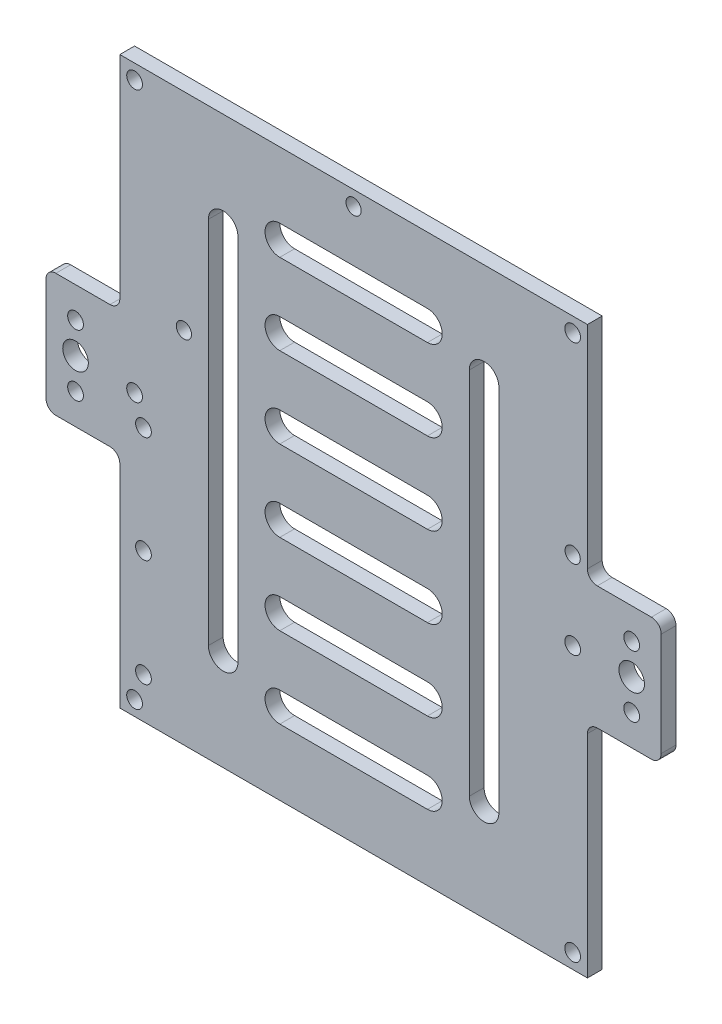
from build123d import *

# Parameters (mm, degrees)
SKETCH4_R           = 1.54999944
SKETCH4_R_2         = 1.6
SKETCH4_R_3         = 2.6
BOSS_EXTRUDE6_DEPTH = 3


with BuildPart() as part:
    # Sketch4 → Boss-Extrude6 (new body)
    with BuildSketch(Plane.XY):
        with BuildLine():
            Line((50.251854725, 14.295018861), (50.251854725, 57.295018861))
            Line((50.251854725, 57.295018861), (-44.769148998, 57.295018861))
            Line((-44.769148998, 57.295018861), (-44.769148998, 14.295018861))
            ThreePointArc((-44.769148998, 14.295018861), (-45.354935436, 12.880805298), (-46.769148998, 12.295018861))
            Line((-46.769148998, 12.295018861), (-57.769148998, 12.295018861))
            ThreePointArc((-57.769148998, 12.295018861), (-59.183362561, 11.709232423), (-59.769148998, 10.295018861))
            Line((-59.769148998, 10.295018861), (-59.769148998, -10.71398001))
            ThreePointArc((-59.769148998, -10.71398001), (-59.183362561, -12.128193573), (-57.769148998, -12.71398001))
            Line((-57.769148998, -12.71398001), (-46.769148998, -12.71398001))
            ThreePointArc((-46.769148998, -12.71398001), (-45.354935436, -13.299766448), (-44.769148998, -14.71398001))
            Line((-44.769148998, -14.71398001), (-44.769148998, -57.71398001))
            Line((-44.769148998, -57.71398001), (50.251854725, -57.71398001))
            Line((50.251854725, -57.71398001), (50.251854725, -14.71398001))
            ThreePointArc((50.251854725, -14.71398001), (50.837641163, -13.299766448), (52.251854725, -12.71398001))
            Line((52.251854725, -12.71398001), (63.251854725, -12.71398001))
            ThreePointArc((63.251854725, -12.71398001), (64.666068287, -12.128193573), (65.251854725, -10.71398001))
            Line((65.251854725, -10.71398001), (65.251854725, 10.295018861))
            ThreePointArc((65.251854725, 10.295018861), (64.666068287, 11.709232423), (63.251854725, 12.295018861))
            Line((63.251854725, 12.295018861), (52.251854725, 12.295018861))
            ThreePointArc((52.251854725, 12.295018861), (50.837641163, 12.880805298), (50.251854725, 14.295018861))
        make_face()
        with Locations((47.251855645, 15.295019041)):
            Circle(SKETCH4_R, mode=Mode.SUBTRACT)
        with Locations((2.741352863, 54.315928454)):
            Circle(SKETCH4_R, mode=Mode.SUBTRACT)
        with Locations((-31.748146375, 15.295019041)):
            Circle(SKETCH4_R, mode=Mode.SUBTRACT)
        with Locations((-41.769148998, -0.71398001)):
            Circle(SKETCH4_R_2, mode=Mode.SUBTRACT)
        with Locations((47.251854725, -0.71398001)):
            Circle(SKETCH4_R_2, mode=Mode.SUBTRACT)
        with Locations((-41.769148998, -54.71398001)):
            Circle(SKETCH4_R_2, mode=Mode.SUBTRACT)
        with Locations((47.251854725, -54.71398001)):
            Circle(SKETCH4_R_2, mode=Mode.SUBTRACT)
        with Locations((-39.969148998, -5.97675003)):
            Circle(SKETCH4_R_2, mode=Mode.SUBTRACT)
        with Locations((-39.969148998, -27.618447294)):
            Circle(SKETCH4_R_2, mode=Mode.SUBTRACT)
        with Locations((-39.969148998, -49.451209991)):
            Circle(SKETCH4_R_2, mode=Mode.SUBTRACT)
        with Locations((59.251854725, -0.209480575)):
            Circle(SKETCH4_R_3, mode=Mode.SUBTRACT)
        with Locations((-41.769148998, 54.315928454)):
            Circle(SKETCH4_R_2, mode=Mode.SUBTRACT)
        with Locations((47.251855645, 54.315928454)):
            Circle(SKETCH4_R_2, mode=Mode.SUBTRACT)
        with Locations((59.251854725, 6.042769143)):
            Circle(SKETCH4_R_2, mode=Mode.SUBTRACT)
        with Locations((59.251854725, -6.461730293)):
            Circle(SKETCH4_R_2, mode=Mode.SUBTRACT)
        with Locations((-53.769148998, -0.209480575)):
            Circle(SKETCH4_R_3, mode=Mode.SUBTRACT)
        with Locations((-53.769148998, 6.042769143)):
            Circle(SKETCH4_R_2, mode=Mode.SUBTRACT)
        with Locations((-53.769148998, -6.461730293)):
            Circle(SKETCH4_R_2, mode=Mode.SUBTRACT)
        with BuildLine():
            Line((-12.258647137, 43.865161879), (17.741352863, 43.865161879))
            ThreePointArc((17.741352863, 43.865161879), (20.741352863, 40.865161879), (17.741352863, 37.865161879))
            Line((17.741352863, 37.865161879), (-12.258647137, 37.865161879))
            ThreePointArc((-12.258647137, 37.865161879), (-15.258647137, 40.865161879), (-12.258647137, 43.865161879))
        make_face(mode=Mode.SUBTRACT)
        with BuildLine():
            Line((-12.258647137, 27.435304897), (17.741352863, 27.435304897))
            ThreePointArc((17.741352863, 27.435304897), (20.741352863, 24.435304897), (17.741352863, 21.435304897))
            Line((17.741352863, 21.435304897), (-12.258647137, 21.435304897))
            ThreePointArc((-12.258647137, 21.435304897), (-15.258647137, 24.435304897), (-12.258647137, 27.435304897))
        make_face(mode=Mode.SUBTRACT)
        with BuildLine():
            Line((-12.258647137, 11.005447916), (17.741352863, 11.005447916))
            ThreePointArc((17.741352863, 11.005447916), (20.741352863, 8.005447916), (17.741352863, 5.005447916))
            Line((17.741352863, 5.005447916), (-12.258647137, 5.005447916))
            ThreePointArc((-12.258647137, 5.005447916), (-15.258647137, 8.005447916), (-12.258647137, 11.005447916))
        make_face(mode=Mode.SUBTRACT)
        with BuildLine():
            Line((-12.258647137, -5.424409066), (17.741352863, -5.424409066))
            ThreePointArc((17.741352863, -5.424409066), (20.741352863, -8.424409066), (17.741352863, -11.424409066))
            Line((17.741352863, -11.424409066), (-12.258647137, -11.424409066))
            ThreePointArc((-12.258647137, -11.424409066), (-15.258647137, -8.424409066), (-12.258647137, -5.424409066))
        make_face(mode=Mode.SUBTRACT)
        with BuildLine():
            Line((-12.258647137, -21.854266047), (17.741352863, -21.854266047))
            ThreePointArc((17.741352863, -21.854266047), (20.741352863, -24.854266047), (17.741352863, -27.854266047))
            Line((17.741352863, -27.854266047), (-12.258647137, -27.854266047))
            ThreePointArc((-12.258647137, -27.854266047), (-15.258647137, -24.854266047), (-12.258647137, -21.854266047))
        make_face(mode=Mode.SUBTRACT)
        with BuildLine():
            Line((-12.258647137, -38.284123029), (17.741352863, -38.284123029))
            ThreePointArc((17.741352863, -38.284123029), (20.741352863, -41.284123029), (17.741352863, -44.284123029))
            Line((17.741352863, -44.284123029), (-12.258647137, -44.284123029))
            ThreePointArc((-12.258647137, -44.284123029), (-15.258647137, -41.284123029), (-12.258647137, -38.284123029))
        make_face(mode=Mode.SUBTRACT)
        with BuildLine():
            Line((-20.769148998, 37.295018861), (-20.769148998, -37.71398001))
            ThreePointArc((-20.769148998, -37.71398001), (-23.769148998, -40.71398001), (-26.769148998, -37.71398001))
            Line((-26.769148998, -37.71398001), (-26.769148998, 37.295018861))
            ThreePointArc((-26.769148998, 37.295018861), (-23.769148998, 40.295018861), (-20.769148998, 37.295018861))
        make_face(mode=Mode.SUBTRACT)
        with BuildLine():
            Line((32.251854725, 37.295018861), (32.251854725, -37.71398001))
            ThreePointArc((32.251854725, -37.71398001), (29.251854725, -40.71398001), (26.251854725, -37.71398001))
            Line((26.251854725, -37.71398001), (26.251854725, 37.295018861))
            ThreePointArc((26.251854725, 37.295018861), (29.251854725, 40.295018861), (32.251854725, 37.295018861))
        make_face(mode=Mode.SUBTRACT)
    extrude(amount=BOSS_EXTRUDE6_DEPTH)


solid = part.part
